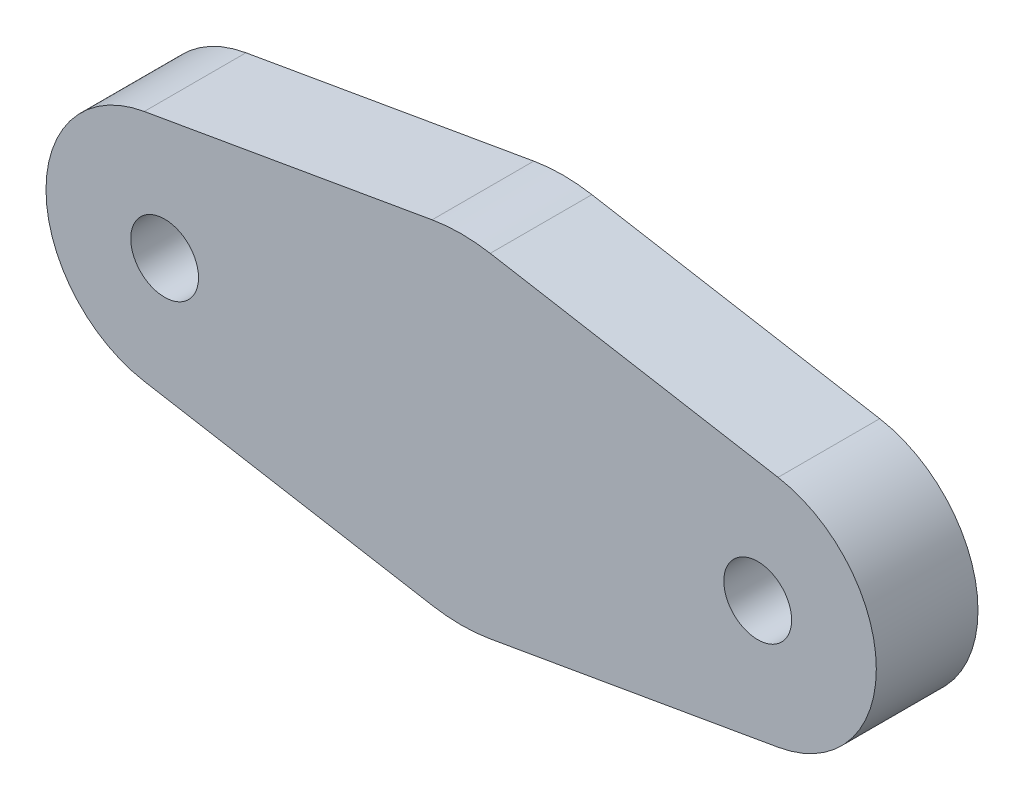
from build123d import *

# Parameters (mm, degrees)
SKETCH_1_R      = 2
EXTRUDE_1_DEPTH = 6


with BuildPart() as part:
    # Эскиз1 → Бобышка-Вытянуть1 (new body)
    with BuildSketch(Plane.XY):
        with BuildLine():
            Line((-1.714285714, 9.851965514), (-18.7, 6.89637586))
            ThreePointArc((-18.7, 6.89637586), (-24.5, 0), (-18.7, -6.89637586))
            Line((-18.7, -6.89637586), (-1.714285714, -9.851965514))
            ThreePointArc((-1.714285714, -9.851965514), (0, -10), (1.714285714, -9.851965514))
            Line((1.714285714, -9.851965514), (18.7, -6.89637586))
            ThreePointArc((18.7, -6.89637586), (24.5, 0), (18.7, 6.89637586))
            Line((18.7, 6.89637586), (1.714285714, 9.851965514))
            ThreePointArc((1.714285714, 9.851965514), (0, 10), (-1.714285714, 9.851965514))
        make_face()
        with Locations((-17.5, 0)):
            Circle(SKETCH_1_R, mode=Mode.SUBTRACT)
        with Locations((17.5, 0)):
            Circle(SKETCH_1_R, mode=Mode.SUBTRACT)
    extrude(amount=EXTRUDE_1_DEPTH)


solid = part.part
